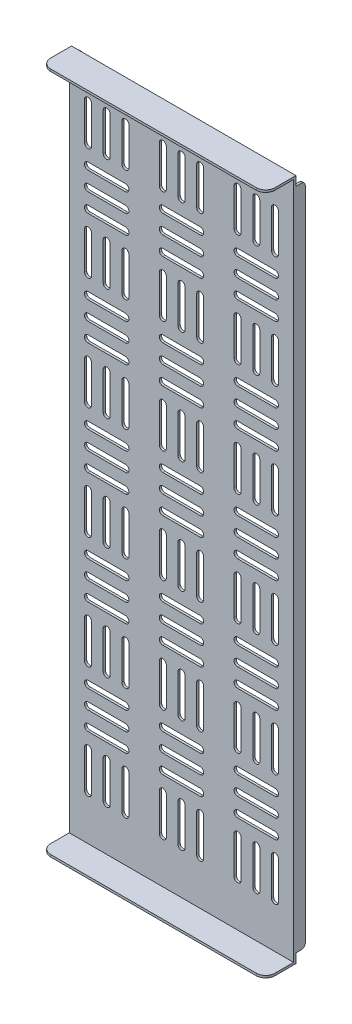
from build123d import *

# Parameters (mm, degrees)
SKETCH1_W           = 152.4
SKETCH1_H           = 463.55
BOSS_EXTRUDE1_DEPTH = 1.524
SKETCH2_W           = 152.4
SKETCH2_H           = 1.524
BOSS_EXTRUDE2_DEPTH = 19.05
FILLET1_R           = 6.35
SKETCH3_W           = 1.524
SKETCH3_H           = 450.85
BOSS_EXTRUDE3_DEPTH = 6.35
FILLET2_R           = 2.54


with BuildPart() as part:
    # Sketch1 → Boss-Extrude1 (new body)
    with BuildSketch(Plane.XY):
        with Locations((76.2, 231.775)):
            Rectangle(SKETCH1_W, SKETCH1_H)
        with BuildLine():
            Line((15.08125, 438.15), (15.08125, 412.75))
            ThreePointArc((15.08125, 412.75), (12.7, 410.36875), (10.31875, 412.75))
            Line((10.31875, 412.75), (10.31875, 438.15))
            ThreePointArc((10.31875, 438.15), (12.7, 440.53125), (15.08125, 438.15))
        make_face(mode=Mode.SUBTRACT)
        with BuildLine():
            Line((27.78125, 438.15), (27.78125, 412.75))
            ThreePointArc((27.78125, 412.75), (25.4, 410.36875), (23.01875, 412.75))
            Line((23.01875, 412.75), (23.01875, 438.15))
            ThreePointArc((23.01875, 438.15), (25.4, 440.53125), (27.78125, 438.15))
        make_face(mode=Mode.SUBTRACT)
        with BuildLine():
            Line((40.48125, 438.15), (40.48125, 412.75))
            ThreePointArc((40.48125, 412.75), (38.1, 410.36875), (35.71875, 412.75))
            Line((35.71875, 412.75), (35.71875, 438.15))
            ThreePointArc((35.71875, 438.15), (38.1, 440.53125), (40.48125, 438.15))
        make_face(mode=Mode.SUBTRACT)
        with BuildLine():
            Line((65.88125, 438.15), (65.88125, 412.75))
            ThreePointArc((65.88125, 412.75), (63.5, 410.36875), (61.11875, 412.75))
            Line((61.11875, 412.75), (61.11875, 438.15))
            ThreePointArc((61.11875, 438.15), (63.5, 440.53125), (65.88125, 438.15))
        make_face(mode=Mode.SUBTRACT)
        with BuildLine():
            Line((78.58125, 438.15), (78.58125, 412.75))
            ThreePointArc((78.58125, 412.75), (76.2, 410.36875), (73.81875, 412.75))
            Line((73.81875, 412.75), (73.81875, 438.15))
            ThreePointArc((73.81875, 438.15), (76.2, 440.53125), (78.58125, 438.15))
        make_face(mode=Mode.SUBTRACT)
        with BuildLine():
            Line((91.28125, 438.15), (91.28125, 412.75))
            ThreePointArc((91.28125, 412.75), (88.9, 410.36875), (86.51875, 412.75))
            Line((86.51875, 412.75), (86.51875, 438.15))
            ThreePointArc((86.51875, 438.15), (88.9, 440.53125), (91.28125, 438.15))
        make_face(mode=Mode.SUBTRACT)
        with BuildLine():
            Line((116.68125, 438.15), (116.68125, 412.75))
            ThreePointArc((116.68125, 412.75), (114.3, 410.36875), (111.91875, 412.75))
            Line((111.91875, 412.75), (111.91875, 438.15))
            ThreePointArc((111.91875, 438.15), (114.3, 440.53125), (116.68125, 438.15))
        make_face(mode=Mode.SUBTRACT)
        with BuildLine():
            Line((129.38125, 438.15), (129.38125, 412.75))
            ThreePointArc((129.38125, 412.75), (127, 410.36875), (124.61875, 412.75))
            Line((124.61875, 412.75), (124.61875, 438.15))
            ThreePointArc((124.61875, 438.15), (127, 440.53125), (129.38125, 438.15))
        make_face(mode=Mode.SUBTRACT)
        with BuildLine():
            Line((142.08125, 438.15), (142.08125, 412.75))
            ThreePointArc((142.08125, 412.75), (139.7, 410.36875), (137.31875, 412.75))
            Line((137.31875, 412.75), (137.31875, 438.15))
            ThreePointArc((137.31875, 438.15), (139.7, 440.53125), (142.08125, 438.15))
        make_face(mode=Mode.SUBTRACT)
        with BuildLine():
            Line((12.7, 402.43125), (38.1, 402.43125))
            ThreePointArc((38.1, 402.43125), (40.48125, 400.05), (38.1, 397.66875))
            Line((38.1, 397.66875), (12.7, 397.66875))
            ThreePointArc((12.7, 397.66875), (10.31875, 400.05), (12.7, 402.43125))
        make_face(mode=Mode.SUBTRACT)
        with BuildLine():
            Line((12.7, 389.73125), (38.1, 389.73125))
            ThreePointArc((38.1, 389.73125), (40.48125, 387.35), (38.1, 384.96875))
            Line((38.1, 384.96875), (12.7, 384.96875))
            ThreePointArc((12.7, 384.96875), (10.31875, 387.35), (12.7, 389.73125))
        make_face(mode=Mode.SUBTRACT)
        with BuildLine():
            Line((12.7, 377.03125), (38.1, 377.03125))
            ThreePointArc((38.1, 377.03125), (40.48125, 374.65), (38.1, 372.26875))
            Line((38.1, 372.26875), (12.7, 372.26875))
            ThreePointArc((12.7, 372.26875), (10.31875, 374.65), (12.7, 377.03125))
        make_face(mode=Mode.SUBTRACT)
        with BuildLine():
            Line((63.5, 402.43125), (88.9, 402.43125))
            ThreePointArc((88.9, 402.43125), (91.28125, 400.05), (88.9, 397.66875))
            Line((88.9, 397.66875), (63.5, 397.66875))
            ThreePointArc((63.5, 397.66875), (61.11875, 400.05), (63.5, 402.43125))
        make_face(mode=Mode.SUBTRACT)
        with BuildLine():
            Line((63.5, 389.73125), (88.9, 389.73125))
            ThreePointArc((88.9, 389.73125), (91.28125, 387.35), (88.9, 384.96875))
            Line((88.9, 384.96875), (63.5, 384.96875))
            ThreePointArc((63.5, 384.96875), (61.11875, 387.35), (63.5, 389.73125))
        make_face(mode=Mode.SUBTRACT)
        with BuildLine():
            Line((63.5, 377.03125), (88.9, 377.03125))
            ThreePointArc((88.9, 377.03125), (91.28125, 374.65), (88.9, 372.26875))
            Line((88.9, 372.26875), (63.5, 372.26875))
            ThreePointArc((63.5, 372.26875), (61.11875, 374.65), (63.5, 377.03125))
        make_face(mode=Mode.SUBTRACT)
        with BuildLine():
            Line((114.3, 402.43125), (139.7, 402.43125))
            ThreePointArc((139.7, 402.43125), (142.08125, 400.05), (139.7, 397.66875))
            Line((139.7, 397.66875), (114.3, 397.66875))
            ThreePointArc((114.3, 397.66875), (111.91875, 400.05), (114.3, 402.43125))
        make_face(mode=Mode.SUBTRACT)
        with BuildLine():
            Line((114.3, 389.73125), (139.7, 389.73125))
            ThreePointArc((139.7, 389.73125), (142.08125, 387.35), (139.7, 384.96875))
            Line((139.7, 384.96875), (114.3, 384.96875))
            ThreePointArc((114.3, 384.96875), (111.91875, 387.35), (114.3, 389.73125))
        make_face(mode=Mode.SUBTRACT)
        with BuildLine():
            Line((114.3, 377.03125), (139.7, 377.03125))
            ThreePointArc((139.7, 377.03125), (142.08125, 374.65), (139.7, 372.26875))
            Line((139.7, 372.26875), (114.3, 372.26875))
            ThreePointArc((114.3, 372.26875), (111.91875, 374.65), (114.3, 377.03125))
        make_face(mode=Mode.SUBTRACT)
        with BuildLine():
            Line((15.08125, 361.95), (15.08125, 336.55))
            ThreePointArc((15.08125, 336.55), (12.7, 334.16875), (10.31875, 336.55))
            Line((10.31875, 336.55), (10.31875, 361.95))
            ThreePointArc((10.31875, 361.95), (12.7, 364.33125), (15.08125, 361.95))
        make_face(mode=Mode.SUBTRACT)
        with BuildLine():
            Line((27.78125, 361.95), (27.78125, 336.55))
            ThreePointArc((27.78125, 336.55), (25.4, 334.16875), (23.01875, 336.55))
            Line((23.01875, 336.55), (23.01875, 361.95))
            ThreePointArc((23.01875, 361.95), (25.4, 364.33125), (27.78125, 361.95))
        make_face(mode=Mode.SUBTRACT)
        with BuildLine():
            Line((40.48125, 361.95), (40.48125, 336.55))
            ThreePointArc((40.48125, 336.55), (38.1, 334.16875), (35.71875, 336.55))
            Line((35.71875, 336.55), (35.71875, 361.95))
            ThreePointArc((35.71875, 361.95), (38.1, 364.33125), (40.48125, 361.95))
        make_face(mode=Mode.SUBTRACT)
        with BuildLine():
            Line((65.88125, 361.95), (65.88125, 336.55))
            ThreePointArc((65.88125, 336.55), (63.5, 334.16875), (61.11875, 336.55))
            Line((61.11875, 336.55), (61.11875, 361.95))
            ThreePointArc((61.11875, 361.95), (63.5, 364.33125), (65.88125, 361.95))
        make_face(mode=Mode.SUBTRACT)
        with BuildLine():
            Line((78.58125, 361.95), (78.58125, 336.55))
            ThreePointArc((78.58125, 336.55), (76.2, 334.16875), (73.81875, 336.55))
            Line((73.81875, 336.55), (73.81875, 361.95))
            ThreePointArc((73.81875, 361.95), (76.2, 364.33125), (78.58125, 361.95))
        make_face(mode=Mode.SUBTRACT)
        with BuildLine():
            Line((91.28125, 361.95), (91.28125, 336.55))
            ThreePointArc((91.28125, 336.55), (88.9, 334.16875), (86.51875, 336.55))
            Line((86.51875, 336.55), (86.51875, 361.95))
            ThreePointArc((86.51875, 361.95), (88.9, 364.33125), (91.28125, 361.95))
        make_face(mode=Mode.SUBTRACT)
        with BuildLine():
            Line((116.68125, 361.95), (116.68125, 336.55))
            ThreePointArc((116.68125, 336.55), (114.3, 334.16875), (111.91875, 336.55))
            Line((111.91875, 336.55), (111.91875, 361.95))
            ThreePointArc((111.91875, 361.95), (114.3, 364.33125), (116.68125, 361.95))
        make_face(mode=Mode.SUBTRACT)
        with BuildLine():
            Line((129.38125, 361.95), (129.38125, 336.55))
            ThreePointArc((129.38125, 336.55), (127, 334.16875), (124.61875, 336.55))
            Line((124.61875, 336.55), (124.61875, 361.95))
            ThreePointArc((124.61875, 361.95), (127, 364.33125), (129.38125, 361.95))
        make_face(mode=Mode.SUBTRACT)
        with BuildLine():
            Line((142.08125, 361.95), (142.08125, 336.55))
            ThreePointArc((142.08125, 336.55), (139.7, 334.16875), (137.31875, 336.55))
            Line((137.31875, 336.55), (137.31875, 361.95))
            ThreePointArc((137.31875, 361.95), (139.7, 364.33125), (142.08125, 361.95))
        make_face(mode=Mode.SUBTRACT)
        with BuildLine():
            Line((12.7, 326.23125), (38.1, 326.23125))
            ThreePointArc((38.1, 326.23125), (40.48125, 323.85), (38.1, 321.46875))
            Line((38.1, 321.46875), (12.7, 321.46875))
            ThreePointArc((12.7, 321.46875), (10.31875, 323.85), (12.7, 326.23125))
        make_face(mode=Mode.SUBTRACT)
        with BuildLine():
            Line((12.7, 313.53125), (38.1, 313.53125))
            ThreePointArc((38.1, 313.53125), (40.48125, 311.15), (38.1, 308.76875))
            Line((38.1, 308.76875), (12.7, 308.76875))
            ThreePointArc((12.7, 308.76875), (10.31875, 311.15), (12.7, 313.53125))
        make_face(mode=Mode.SUBTRACT)
        with BuildLine():
            Line((12.7, 300.83125), (38.1, 300.83125))
            ThreePointArc((38.1, 300.83125), (40.48125, 298.45), (38.1, 296.06875))
            Line((38.1, 296.06875), (12.7, 296.06875))
            ThreePointArc((12.7, 296.06875), (10.31875, 298.45), (12.7, 300.83125))
        make_face(mode=Mode.SUBTRACT)
        with BuildLine():
            Line((63.5, 326.23125), (88.9, 326.23125))
            ThreePointArc((88.9, 326.23125), (91.28125, 323.85), (88.9, 321.46875))
            Line((88.9, 321.46875), (63.5, 321.46875))
            ThreePointArc((63.5, 321.46875), (61.11875, 323.85), (63.5, 326.23125))
        make_face(mode=Mode.SUBTRACT)
        with BuildLine():
            Line((63.5, 313.53125), (88.9, 313.53125))
            ThreePointArc((88.9, 313.53125), (91.28125, 311.15), (88.9, 308.76875))
            Line((88.9, 308.76875), (63.5, 308.76875))
            ThreePointArc((63.5, 308.76875), (61.11875, 311.15), (63.5, 313.53125))
        make_face(mode=Mode.SUBTRACT)
        with BuildLine():
            Line((63.5, 300.83125), (88.9, 300.83125))
            ThreePointArc((88.9, 300.83125), (91.28125, 298.45), (88.9, 296.06875))
            Line((88.9, 296.06875), (63.5, 296.06875))
            ThreePointArc((63.5, 296.06875), (61.11875, 298.45), (63.5, 300.83125))
        make_face(mode=Mode.SUBTRACT)
        with BuildLine():
            Line((114.3, 326.23125), (139.7, 326.23125))
            ThreePointArc((139.7, 326.23125), (142.08125, 323.85), (139.7, 321.46875))
            Line((139.7, 321.46875), (114.3, 321.46875))
            ThreePointArc((114.3, 321.46875), (111.91875, 323.85), (114.3, 326.23125))
        make_face(mode=Mode.SUBTRACT)
        with BuildLine():
            Line((114.3, 313.53125), (139.7, 313.53125))
            ThreePointArc((139.7, 313.53125), (142.08125, 311.15), (139.7, 308.76875))
            Line((139.7, 308.76875), (114.3, 308.76875))
            ThreePointArc((114.3, 308.76875), (111.91875, 311.15), (114.3, 313.53125))
        make_face(mode=Mode.SUBTRACT)
        with BuildLine():
            Line((114.3, 300.83125), (139.7, 300.83125))
            ThreePointArc((139.7, 300.83125), (142.08125, 298.45), (139.7, 296.06875))
            Line((139.7, 296.06875), (114.3, 296.06875))
            ThreePointArc((114.3, 296.06875), (111.91875, 298.45), (114.3, 300.83125))
        make_face(mode=Mode.SUBTRACT)
        with BuildLine():
            Line((15.08125, 285.75), (15.08125, 260.35))
            ThreePointArc((15.08125, 260.35), (12.7, 257.96875), (10.31875, 260.35))
            Line((10.31875, 260.35), (10.31875, 285.75))
            ThreePointArc((10.31875, 285.75), (12.7, 288.13125), (15.08125, 285.75))
        make_face(mode=Mode.SUBTRACT)
        with BuildLine():
            Line((27.78125, 285.75), (27.78125, 260.35))
            ThreePointArc((27.78125, 260.35), (25.4, 257.96875), (23.01875, 260.35))
            Line((23.01875, 260.35), (23.01875, 285.75))
            ThreePointArc((23.01875, 285.75), (25.4, 288.13125), (27.78125, 285.75))
        make_face(mode=Mode.SUBTRACT)
        with BuildLine():
            Line((40.48125, 285.75), (40.48125, 260.35))
            ThreePointArc((40.48125, 260.35), (38.1, 257.96875), (35.71875, 260.35))
            Line((35.71875, 260.35), (35.71875, 285.75))
            ThreePointArc((35.71875, 285.75), (38.1, 288.13125), (40.48125, 285.75))
        make_face(mode=Mode.SUBTRACT)
        with BuildLine():
            Line((65.88125, 285.75), (65.88125, 260.35))
            ThreePointArc((65.88125, 260.35), (63.5, 257.96875), (61.11875, 260.35))
            Line((61.11875, 260.35), (61.11875, 285.75))
            ThreePointArc((61.11875, 285.75), (63.5, 288.13125), (65.88125, 285.75))
        make_face(mode=Mode.SUBTRACT)
        with BuildLine():
            Line((78.58125, 285.75), (78.58125, 260.35))
            ThreePointArc((78.58125, 260.35), (76.2, 257.96875), (73.81875, 260.35))
            Line((73.81875, 260.35), (73.81875, 285.75))
            ThreePointArc((73.81875, 285.75), (76.2, 288.13125), (78.58125, 285.75))
        make_face(mode=Mode.SUBTRACT)
        with BuildLine():
            Line((91.28125, 285.75), (91.28125, 260.35))
            ThreePointArc((91.28125, 260.35), (88.9, 257.96875), (86.51875, 260.35))
            Line((86.51875, 260.35), (86.51875, 285.75))
            ThreePointArc((86.51875, 285.75), (88.9, 288.13125), (91.28125, 285.75))
        make_face(mode=Mode.SUBTRACT)
        with BuildLine():
            Line((116.68125, 285.75), (116.68125, 260.35))
            ThreePointArc((116.68125, 260.35), (114.3, 257.96875), (111.91875, 260.35))
            Line((111.91875, 260.35), (111.91875, 285.75))
            ThreePointArc((111.91875, 285.75), (114.3, 288.13125), (116.68125, 285.75))
        make_face(mode=Mode.SUBTRACT)
        with BuildLine():
            Line((129.38125, 285.75), (129.38125, 260.35))
            ThreePointArc((129.38125, 260.35), (127, 257.96875), (124.61875, 260.35))
            Line((124.61875, 260.35), (124.61875, 285.75))
            ThreePointArc((124.61875, 285.75), (127, 288.13125), (129.38125, 285.75))
        make_face(mode=Mode.SUBTRACT)
        with BuildLine():
            Line((142.08125, 285.75), (142.08125, 260.35))
            ThreePointArc((142.08125, 260.35), (139.7, 257.96875), (137.31875, 260.35))
            Line((137.31875, 260.35), (137.31875, 285.75))
            ThreePointArc((137.31875, 285.75), (139.7, 288.13125), (142.08125, 285.75))
        make_face(mode=Mode.SUBTRACT)
        with BuildLine():
            Line((12.7, 250.03125), (38.1, 250.03125))
            ThreePointArc((38.1, 250.03125), (40.48125, 247.65), (38.1, 245.26875))
            Line((38.1, 245.26875), (12.7, 245.26875))
            ThreePointArc((12.7, 245.26875), (10.31875, 247.65), (12.7, 250.03125))
        make_face(mode=Mode.SUBTRACT)
        with BuildLine():
            Line((12.7, 237.33125), (38.1, 237.33125))
            ThreePointArc((38.1, 237.33125), (40.48125, 234.95), (38.1, 232.56875))
            Line((38.1, 232.56875), (12.7, 232.56875))
            ThreePointArc((12.7, 232.56875), (10.31875, 234.95), (12.7, 237.33125))
        make_face(mode=Mode.SUBTRACT)
        with BuildLine():
            Line((12.7, 224.63125), (38.1, 224.63125))
            ThreePointArc((38.1, 224.63125), (40.48125, 222.25), (38.1, 219.86875))
            Line((38.1, 219.86875), (12.7, 219.86875))
            ThreePointArc((12.7, 219.86875), (10.31875, 222.25), (12.7, 224.63125))
        make_face(mode=Mode.SUBTRACT)
        with BuildLine():
            Line((63.5, 250.03125), (88.9, 250.03125))
            ThreePointArc((88.9, 250.03125), (91.28125, 247.65), (88.9, 245.26875))
            Line((88.9, 245.26875), (63.5, 245.26875))
            ThreePointArc((63.5, 245.26875), (61.11875, 247.65), (63.5, 250.03125))
        make_face(mode=Mode.SUBTRACT)
        with BuildLine():
            Line((63.5, 237.33125), (88.9, 237.33125))
            ThreePointArc((88.9, 237.33125), (91.28125, 234.95), (88.9, 232.56875))
            Line((88.9, 232.56875), (63.5, 232.56875))
            ThreePointArc((63.5, 232.56875), (61.11875, 234.95), (63.5, 237.33125))
        make_face(mode=Mode.SUBTRACT)
        with BuildLine():
            Line((63.5, 224.63125), (88.9, 224.63125))
            ThreePointArc((88.9, 224.63125), (91.28125, 222.25), (88.9, 219.86875))
            Line((88.9, 219.86875), (63.5, 219.86875))
            ThreePointArc((63.5, 219.86875), (61.11875, 222.25), (63.5, 224.63125))
        make_face(mode=Mode.SUBTRACT)
        with BuildLine():
            Line((114.3, 250.03125), (139.7, 250.03125))
            ThreePointArc((139.7, 250.03125), (142.08125, 247.65), (139.7, 245.26875))
            Line((139.7, 245.26875), (114.3, 245.26875))
            ThreePointArc((114.3, 245.26875), (111.91875, 247.65), (114.3, 250.03125))
        make_face(mode=Mode.SUBTRACT)
        with BuildLine():
            Line((114.3, 237.33125), (139.7, 237.33125))
            ThreePointArc((139.7, 237.33125), (142.08125, 234.95), (139.7, 232.56875))
            Line((139.7, 232.56875), (114.3, 232.56875))
            ThreePointArc((114.3, 232.56875), (111.91875, 234.95), (114.3, 237.33125))
        make_face(mode=Mode.SUBTRACT)
        with BuildLine():
            Line((114.3, 224.63125), (139.7, 224.63125))
            ThreePointArc((139.7, 224.63125), (142.08125, 222.25), (139.7, 219.86875))
            Line((139.7, 219.86875), (114.3, 219.86875))
            ThreePointArc((114.3, 219.86875), (111.91875, 222.25), (114.3, 224.63125))
        make_face(mode=Mode.SUBTRACT)
        with BuildLine():
            Line((15.08125, 209.55), (15.08125, 184.15))
            ThreePointArc((15.08125, 184.15), (12.7, 181.76875), (10.31875, 184.15))
            Line((10.31875, 184.15), (10.31875, 209.55))
            ThreePointArc((10.31875, 209.55), (12.7, 211.93125), (15.08125, 209.55))
        make_face(mode=Mode.SUBTRACT)
        with BuildLine():
            Line((27.78125, 209.55), (27.78125, 184.15))
            ThreePointArc((27.78125, 184.15), (25.4, 181.76875), (23.01875, 184.15))
            Line((23.01875, 184.15), (23.01875, 209.55))
            ThreePointArc((23.01875, 209.55), (25.4, 211.93125), (27.78125, 209.55))
        make_face(mode=Mode.SUBTRACT)
        with BuildLine():
            Line((40.48125, 209.55), (40.48125, 184.15))
            ThreePointArc((40.48125, 184.15), (38.1, 181.76875), (35.71875, 184.15))
            Line((35.71875, 184.15), (35.71875, 209.55))
            ThreePointArc((35.71875, 209.55), (38.1, 211.93125), (40.48125, 209.55))
        make_face(mode=Mode.SUBTRACT)
        with BuildLine():
            Line((65.88125, 209.55), (65.88125, 184.15))
            ThreePointArc((65.88125, 184.15), (63.5, 181.76875), (61.11875, 184.15))
            Line((61.11875, 184.15), (61.11875, 209.55))
            ThreePointArc((61.11875, 209.55), (63.5, 211.93125), (65.88125, 209.55))
        make_face(mode=Mode.SUBTRACT)
        with BuildLine():
            Line((78.58125, 209.55), (78.58125, 184.15))
            ThreePointArc((78.58125, 184.15), (76.2, 181.76875), (73.81875, 184.15))
            Line((73.81875, 184.15), (73.81875, 209.55))
            ThreePointArc((73.81875, 209.55), (76.2, 211.93125), (78.58125, 209.55))
        make_face(mode=Mode.SUBTRACT)
        with BuildLine():
            Line((91.28125, 209.55), (91.28125, 184.15))
            ThreePointArc((91.28125, 184.15), (88.9, 181.76875), (86.51875, 184.15))
            Line((86.51875, 184.15), (86.51875, 209.55))
            ThreePointArc((86.51875, 209.55), (88.9, 211.93125), (91.28125, 209.55))
        make_face(mode=Mode.SUBTRACT)
        with BuildLine():
            Line((116.68125, 209.55), (116.68125, 184.15))
            ThreePointArc((116.68125, 184.15), (114.3, 181.76875), (111.91875, 184.15))
            Line((111.91875, 184.15), (111.91875, 209.55))
            ThreePointArc((111.91875, 209.55), (114.3, 211.93125), (116.68125, 209.55))
        make_face(mode=Mode.SUBTRACT)
        with BuildLine():
            Line((129.38125, 209.55), (129.38125, 184.15))
            ThreePointArc((129.38125, 184.15), (127, 181.76875), (124.61875, 184.15))
            Line((124.61875, 184.15), (124.61875, 209.55))
            ThreePointArc((124.61875, 209.55), (127, 211.93125), (129.38125, 209.55))
        make_face(mode=Mode.SUBTRACT)
        with BuildLine():
            Line((142.08125, 209.55), (142.08125, 184.15))
            ThreePointArc((142.08125, 184.15), (139.7, 181.76875), (137.31875, 184.15))
            Line((137.31875, 184.15), (137.31875, 209.55))
            ThreePointArc((137.31875, 209.55), (139.7, 211.93125), (142.08125, 209.55))
        make_face(mode=Mode.SUBTRACT)
        with BuildLine():
            Line((12.7, 173.83125), (38.1, 173.83125))
            ThreePointArc((38.1, 173.83125), (40.48125, 171.45), (38.1, 169.06875))
            Line((38.1, 169.06875), (12.7, 169.06875))
            ThreePointArc((12.7, 169.06875), (10.31875, 171.45), (12.7, 173.83125))
        make_face(mode=Mode.SUBTRACT)
        with BuildLine():
            Line((12.7, 161.13125), (38.1, 161.13125))
            ThreePointArc((38.1, 161.13125), (40.48125, 158.75), (38.1, 156.36875))
            Line((38.1, 156.36875), (12.7, 156.36875))
            ThreePointArc((12.7, 156.36875), (10.31875, 158.75), (12.7, 161.13125))
        make_face(mode=Mode.SUBTRACT)
        with BuildLine():
            Line((12.7, 148.43125), (38.1, 148.43125))
            ThreePointArc((38.1, 148.43125), (40.48125, 146.05), (38.1, 143.66875))
            Line((38.1, 143.66875), (12.7, 143.66875))
            ThreePointArc((12.7, 143.66875), (10.31875, 146.05), (12.7, 148.43125))
        make_face(mode=Mode.SUBTRACT)
        with BuildLine():
            Line((63.5, 173.83125), (88.9, 173.83125))
            ThreePointArc((88.9, 173.83125), (91.28125, 171.45), (88.9, 169.06875))
            Line((88.9, 169.06875), (63.5, 169.06875))
            ThreePointArc((63.5, 169.06875), (61.11875, 171.45), (63.5, 173.83125))
        make_face(mode=Mode.SUBTRACT)
        with BuildLine():
            Line((63.5, 161.13125), (88.9, 161.13125))
            ThreePointArc((88.9, 161.13125), (91.28125, 158.75), (88.9, 156.36875))
            Line((88.9, 156.36875), (63.5, 156.36875))
            ThreePointArc((63.5, 156.36875), (61.11875, 158.75), (63.5, 161.13125))
        make_face(mode=Mode.SUBTRACT)
        with BuildLine():
            Line((63.5, 148.43125), (88.9, 148.43125))
            ThreePointArc((88.9, 148.43125), (91.28125, 146.05), (88.9, 143.66875))
            Line((88.9, 143.66875), (63.5, 143.66875))
            ThreePointArc((63.5, 143.66875), (61.11875, 146.05), (63.5, 148.43125))
        make_face(mode=Mode.SUBTRACT)
        with BuildLine():
            Line((114.3, 173.83125), (139.7, 173.83125))
            ThreePointArc((139.7, 173.83125), (142.08125, 171.45), (139.7, 169.06875))
            Line((139.7, 169.06875), (114.3, 169.06875))
            ThreePointArc((114.3, 169.06875), (111.91875, 171.45), (114.3, 173.83125))
        make_face(mode=Mode.SUBTRACT)
        with BuildLine():
            Line((114.3, 161.13125), (139.7, 161.13125))
            ThreePointArc((139.7, 161.13125), (142.08125, 158.75), (139.7, 156.36875))
            Line((139.7, 156.36875), (114.3, 156.36875))
            ThreePointArc((114.3, 156.36875), (111.91875, 158.75), (114.3, 161.13125))
        make_face(mode=Mode.SUBTRACT)
        with BuildLine():
            Line((114.3, 148.43125), (139.7, 148.43125))
            ThreePointArc((139.7, 148.43125), (142.08125, 146.05), (139.7, 143.66875))
            Line((139.7, 143.66875), (114.3, 143.66875))
            ThreePointArc((114.3, 143.66875), (111.91875, 146.05), (114.3, 148.43125))
        make_face(mode=Mode.SUBTRACT)
        with BuildLine():
            Line((15.08125, 133.35), (15.08125, 107.95))
            ThreePointArc((15.08125, 107.95), (12.7, 105.56875), (10.31875, 107.95))
            Line((10.31875, 107.95), (10.31875, 133.35))
            ThreePointArc((10.31875, 133.35), (12.7, 135.73125), (15.08125, 133.35))
        make_face(mode=Mode.SUBTRACT)
        with BuildLine():
            Line((27.78125, 133.35), (27.78125, 107.95))
            ThreePointArc((27.78125, 107.95), (25.4, 105.56875), (23.01875, 107.95))
            Line((23.01875, 107.95), (23.01875, 133.35))
            ThreePointArc((23.01875, 133.35), (25.4, 135.73125), (27.78125, 133.35))
        make_face(mode=Mode.SUBTRACT)
        with BuildLine():
            Line((40.48125, 133.35), (40.48125, 107.95))
            ThreePointArc((40.48125, 107.95), (38.1, 105.56875), (35.71875, 107.95))
            Line((35.71875, 107.95), (35.71875, 133.35))
            ThreePointArc((35.71875, 133.35), (38.1, 135.73125), (40.48125, 133.35))
        make_face(mode=Mode.SUBTRACT)
        with BuildLine():
            Line((65.88125, 133.35), (65.88125, 107.95))
            ThreePointArc((65.88125, 107.95), (63.5, 105.56875), (61.11875, 107.95))
            Line((61.11875, 107.95), (61.11875, 133.35))
            ThreePointArc((61.11875, 133.35), (63.5, 135.73125), (65.88125, 133.35))
        make_face(mode=Mode.SUBTRACT)
        with BuildLine():
            Line((78.58125, 133.35), (78.58125, 107.95))
            ThreePointArc((78.58125, 107.95), (76.2, 105.56875), (73.81875, 107.95))
            Line((73.81875, 107.95), (73.81875, 133.35))
            ThreePointArc((73.81875, 133.35), (76.2, 135.73125), (78.58125, 133.35))
        make_face(mode=Mode.SUBTRACT)
        with BuildLine():
            Line((91.28125, 133.35), (91.28125, 107.95))
            ThreePointArc((91.28125, 107.95), (88.9, 105.56875), (86.51875, 107.95))
            Line((86.51875, 107.95), (86.51875, 133.35))
            ThreePointArc((86.51875, 133.35), (88.9, 135.73125), (91.28125, 133.35))
        make_face(mode=Mode.SUBTRACT)
        with BuildLine():
            Line((116.68125, 133.35), (116.68125, 107.95))
            ThreePointArc((116.68125, 107.95), (114.3, 105.56875), (111.91875, 107.95))
            Line((111.91875, 107.95), (111.91875, 133.35))
            ThreePointArc((111.91875, 133.35), (114.3, 135.73125), (116.68125, 133.35))
        make_face(mode=Mode.SUBTRACT)
        with BuildLine():
            Line((129.38125, 133.35), (129.38125, 107.95))
            ThreePointArc((129.38125, 107.95), (127, 105.56875), (124.61875, 107.95))
            Line((124.61875, 107.95), (124.61875, 133.35))
            ThreePointArc((124.61875, 133.35), (127, 135.73125), (129.38125, 133.35))
        make_face(mode=Mode.SUBTRACT)
        with BuildLine():
            Line((142.08125, 133.35), (142.08125, 107.95))
            ThreePointArc((142.08125, 107.95), (139.7, 105.56875), (137.31875, 107.95))
            Line((137.31875, 107.95), (137.31875, 133.35))
            ThreePointArc((137.31875, 133.35), (139.7, 135.73125), (142.08125, 133.35))
        make_face(mode=Mode.SUBTRACT)
        with BuildLine():
            Line((12.7, 97.63125), (38.1, 97.63125))
            ThreePointArc((38.1, 97.63125), (40.48125, 95.25), (38.1, 92.86875))
            Line((38.1, 92.86875), (12.7, 92.86875))
            ThreePointArc((12.7, 92.86875), (10.31875, 95.25), (12.7, 97.63125))
        make_face(mode=Mode.SUBTRACT)
        with BuildLine():
            Line((12.7, 84.93125), (38.1, 84.93125))
            ThreePointArc((38.1, 84.93125), (40.48125, 82.55), (38.1, 80.16875))
            Line((38.1, 80.16875), (12.7, 80.16875))
            ThreePointArc((12.7, 80.16875), (10.31875, 82.55), (12.7, 84.93125))
        make_face(mode=Mode.SUBTRACT)
        with BuildLine():
            Line((12.7, 72.23125), (38.1, 72.23125))
            ThreePointArc((38.1, 72.23125), (40.48125, 69.85), (38.1, 67.46875))
            Line((38.1, 67.46875), (12.7, 67.46875))
            ThreePointArc((12.7, 67.46875), (10.31875, 69.85), (12.7, 72.23125))
        make_face(mode=Mode.SUBTRACT)
        with BuildLine():
            Line((63.5, 97.63125), (88.9, 97.63125))
            ThreePointArc((88.9, 97.63125), (91.28125, 95.25), (88.9, 92.86875))
            Line((88.9, 92.86875), (63.5, 92.86875))
            ThreePointArc((63.5, 92.86875), (61.11875, 95.25), (63.5, 97.63125))
        make_face(mode=Mode.SUBTRACT)
        with BuildLine():
            Line((63.5, 84.93125), (88.9, 84.93125))
            ThreePointArc((88.9, 84.93125), (91.28125, 82.55), (88.9, 80.16875))
            Line((88.9, 80.16875), (63.5, 80.16875))
            ThreePointArc((63.5, 80.16875), (61.11875, 82.55), (63.5, 84.93125))
        make_face(mode=Mode.SUBTRACT)
        with BuildLine():
            Line((63.5, 72.23125), (88.9, 72.23125))
            ThreePointArc((88.9, 72.23125), (91.28125, 69.85), (88.9, 67.46875))
            Line((88.9, 67.46875), (63.5, 67.46875))
            ThreePointArc((63.5, 67.46875), (61.11875, 69.85), (63.5, 72.23125))
        make_face(mode=Mode.SUBTRACT)
        with BuildLine():
            Line((114.3, 97.63125), (139.7, 97.63125))
            ThreePointArc((139.7, 97.63125), (142.08125, 95.25), (139.7, 92.86875))
            Line((139.7, 92.86875), (114.3, 92.86875))
            ThreePointArc((114.3, 92.86875), (111.91875, 95.25), (114.3, 97.63125))
        make_face(mode=Mode.SUBTRACT)
        with BuildLine():
            Line((114.3, 84.93125), (139.7, 84.93125))
            ThreePointArc((139.7, 84.93125), (142.08125, 82.55), (139.7, 80.16875))
            Line((139.7, 80.16875), (114.3, 80.16875))
            ThreePointArc((114.3, 80.16875), (111.91875, 82.55), (114.3, 84.93125))
        make_face(mode=Mode.SUBTRACT)
        with BuildLine():
            Line((114.3, 72.23125), (139.7, 72.23125))
            ThreePointArc((139.7, 72.23125), (142.08125, 69.85), (139.7, 67.46875))
            Line((139.7, 67.46875), (114.3, 67.46875))
            ThreePointArc((114.3, 67.46875), (111.91875, 69.85), (114.3, 72.23125))
        make_face(mode=Mode.SUBTRACT)
        with BuildLine():
            Line((15.08125, 57.15), (15.08125, 31.75))
            ThreePointArc((15.08125, 31.75), (12.7, 29.36875), (10.31875, 31.75))
            Line((10.31875, 31.75), (10.31875, 57.15))
            ThreePointArc((10.31875, 57.15), (12.7, 59.53125), (15.08125, 57.15))
        make_face(mode=Mode.SUBTRACT)
        with BuildLine():
            Line((27.78125, 57.15), (27.78125, 31.75))
            ThreePointArc((27.78125, 31.75), (25.4, 29.36875), (23.01875, 31.75))
            Line((23.01875, 31.75), (23.01875, 57.15))
            ThreePointArc((23.01875, 57.15), (25.4, 59.53125), (27.78125, 57.15))
        make_face(mode=Mode.SUBTRACT)
        with BuildLine():
            Line((40.48125, 57.15), (40.48125, 31.75))
            ThreePointArc((40.48125, 31.75), (38.1, 29.36875), (35.71875, 31.75))
            Line((35.71875, 31.75), (35.71875, 57.15))
            ThreePointArc((35.71875, 57.15), (38.1, 59.53125), (40.48125, 57.15))
        make_face(mode=Mode.SUBTRACT)
        with BuildLine():
            Line((65.88125, 57.15), (65.88125, 31.75))
            ThreePointArc((65.88125, 31.75), (63.5, 29.36875), (61.11875, 31.75))
            Line((61.11875, 31.75), (61.11875, 57.15))
            ThreePointArc((61.11875, 57.15), (63.5, 59.53125), (65.88125, 57.15))
        make_face(mode=Mode.SUBTRACT)
        with BuildLine():
            Line((78.58125, 57.15), (78.58125, 31.75))
            ThreePointArc((78.58125, 31.75), (76.2, 29.36875), (73.81875, 31.75))
            Line((73.81875, 31.75), (73.81875, 57.15))
            ThreePointArc((73.81875, 57.15), (76.2, 59.53125), (78.58125, 57.15))
        make_face(mode=Mode.SUBTRACT)
        with BuildLine():
            Line((91.28125, 57.15), (91.28125, 31.75))
            ThreePointArc((91.28125, 31.75), (88.9, 29.36875), (86.51875, 31.75))
            Line((86.51875, 31.75), (86.51875, 57.15))
            ThreePointArc((86.51875, 57.15), (88.9, 59.53125), (91.28125, 57.15))
        make_face(mode=Mode.SUBTRACT)
        with BuildLine():
            Line((116.68125, 57.15), (116.68125, 31.75))
            ThreePointArc((116.68125, 31.75), (114.3, 29.36875), (111.91875, 31.75))
            Line((111.91875, 31.75), (111.91875, 57.15))
            ThreePointArc((111.91875, 57.15), (114.3, 59.53125), (116.68125, 57.15))
        make_face(mode=Mode.SUBTRACT)
        with BuildLine():
            Line((129.38125, 57.15), (129.38125, 31.75))
            ThreePointArc((129.38125, 31.75), (127, 29.36875), (124.61875, 31.75))
            Line((124.61875, 31.75), (124.61875, 57.15))
            ThreePointArc((124.61875, 57.15), (127, 59.53125), (129.38125, 57.15))
        make_face(mode=Mode.SUBTRACT)
        with BuildLine():
            Line((142.08125, 57.15), (142.08125, 31.75))
            ThreePointArc((142.08125, 31.75), (139.7, 29.36875), (137.31875, 31.75))
            Line((137.31875, 31.75), (137.31875, 57.15))
            ThreePointArc((137.31875, 57.15), (139.7, 59.53125), (142.08125, 57.15))
        make_face(mode=Mode.SUBTRACT)
    extrude(amount=BOSS_EXTRUDE1_DEPTH)

    # Sketch2 → Boss-Extrude2 (add)
    with BuildSketch(Plane.XY.offset(1.524)):
        with Locations((76.2, 462.788)):
            Rectangle(SKETCH2_W, SKETCH2_H)
        with Locations((76.2, 0.762)):
            Rectangle(SKETCH2_W, SKETCH2_H)
    extrude(amount=BOSS_EXTRUDE2_DEPTH)

    # Fillet1
    fillet1_edges = [part.edges().sort_by_distance(p)[0] for p in [
        (0, 462.788, 20.574),
        (152.4, 462.788, 20.574),
        (0, 0.762, 20.574),
        (152.4, 0.762, 20.574),
    ]]
    fillet(fillet1_edges, radius=FILLET1_R)

    # Sketch3 → Boss-Extrude3 (add)
    with BuildSketch(Plane(origin=(0, 0, 0), x_dir=(-1, 0, 0), z_dir=(0, 0, -1))):
        with Locations((-151.638, 231.775)):
            Rectangle(SKETCH3_W, SKETCH3_H)
        with Locations((-0.762, 233.459909725)):
            Rectangle(SKETCH3_W, SKETCH3_H)
    extrude(amount=BOSS_EXTRUDE3_DEPTH)

    # Fillet2
    fillet2_edges = [part.edges().sort_by_distance(p)[0] for p in [
        (151.638, 6.35, -6.35),
        (151.638, 457.2, -6.35),
        (0.762, 458.884909725, -6.35),
        (0.762, 8.034909725, -6.35),
    ]]
    fillet(fillet2_edges, radius=FILLET2_R)


solid = part.part
